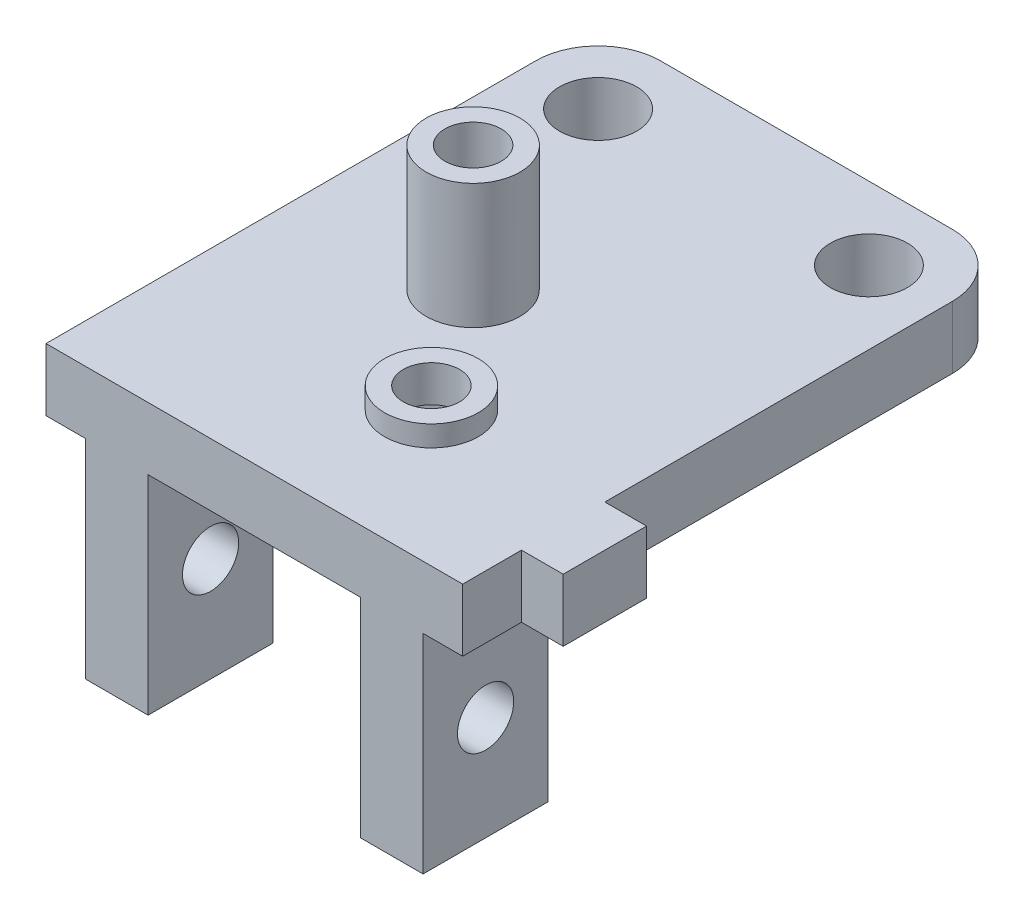
from build123d import *

# Parameters (mm, degrees)
BOSS_EXTRUDE1_DEPTH   = 6
SKETCH16_R            = 4.5
BOSS_EXTRUDE3_DEPTH   = 12
SKETCH16_3_R          = 4.5
BOSS_EXTRUDE4_DEPTH   = 2
CUT_EXTRUDE1_DEPTH    = 4.5
F_5_4MM_DOWEL_HOLE1_D = 5.4
F_7_4MM_DOWEL_HOLE2_D = 7.4
SKETCH2_W             = 6
SKETCH2_H             = 12
BOSS_EXTRUDE2_DEPTH   = 20
F_5_4MM_DOWEL_HOLE3_D = 5.4
FILLET1_R             = 6


with BuildPart() as part:
    # Sketch1 → Boss-Extrude1 (new body)
    with BuildSketch(Plane(origin=(0, 0, 0), x_dir=(1, 0, 0), z_dir=(0, 1, 0))):
        Polygon((40, 5.65), (40, 0), (0, 0), (0, 53), (40, 53), (40, 13.65), (44, 13.65), (44, 5.65), align=None)
    extrude(amount=BOSS_EXTRUDE1_DEPTH)

    # Sketch16 → Boss-Extrude3 (add)
    with BuildSketch(Plane(origin=(0, 6, 0), x_dir=(1, 0, 0), z_dir=(0, 1, 0))):
        with Locations((16, 25)):
            Circle(SKETCH16_R)
    extrude(amount=BOSS_EXTRUDE3_DEPTH)

    # Sketch16_3 → Boss-Extrude4 (add)
    with BuildSketch(Plane(origin=(0, 6, 0), x_dir=(1, 0, 0), z_dir=(0, 1, 0))):
        with Locations((24, 13)):
            Circle(SKETCH16_3_R)
    extrude(amount=BOSS_EXTRUDE4_DEPTH)

    # Sketch12 → Cut-Extrude1 (cut)
    with BuildSketch(Plane.XZ):
        Polygon((28.2, -10.575128869), (24, -8.150257739), (19.8, -10.575128869), (19.8, -15.424871131), (24, -17.849742261), (28.2, -15.424871131), align=None)
        Polygon((16, -20.150257739), (11.8, -22.575128869), (11.8, -27.424871131), (16, -29.849742261), (20.2, -27.424871131), (20.2, -22.575128869), align=None)
    extrude(amount=-CUT_EXTRUDE1_DEPTH, mode=Mode.SUBTRACT)

    # Ø5.4mm Dowel Hole1 (through all)
    with Locations(Plane(origin=(0, 0, 0), x_dir=(-1, 0, 0), z_dir=(0, -1, 0))):
        with Locations((-16, 25), (-24, 13)):
            Hole(F_5_4MM_DOWEL_HOLE1_D / 2)

    # Ø7.4mm Dowel Hole2 (through all)
    with Locations(Plane(origin=(0, 6, 0), x_dir=(1, 0, 0), z_dir=(0, 1, 0))):
        with Locations((7, 46)):
            f_7_4mm_dowel_hole2 = Hole(F_7_4MM_DOWEL_HOLE2_D / 2)

    # Sketch2 → Boss-Extrude2 (add)
    with BuildSketch(Plane.XZ):
        with Locations((6.8, -6)):
            Rectangle(SKETCH2_W, SKETCH2_H)
    boss_extrude2 = extrude(amount=BOSS_EXTRUDE2_DEPTH)

    # Ø5.4mm Dowel Hole3 (through all)
    with Locations(Plane(origin=(9.8, 0, 0), x_dir=(0, 0, -1), z_dir=(1, 0, 0))):
        with Locations((6, -10)):
            f_5_4mm_dowel_hole3 = Hole(F_5_4MM_DOWEL_HOLE3_D / 2)

    # Mirror1: Ø7.4mm Dowel Hole2, Boss-Extrude2, Ø5.4mm Dowel Hole3 across plane
    add(f_7_4mm_dowel_hole2.mirror(Plane(origin=(20, 0, 0), x_dir=(0, 0, 1), z_dir=(1, 0, 0))), mode=Mode.SUBTRACT)
    add(boss_extrude2.mirror(Plane(origin=(20, 0, 0), x_dir=(0, 0, 1), z_dir=(1, 0, 0))))
    add(f_5_4mm_dowel_hole3.mirror(Plane(origin=(20, 0, 0), x_dir=(0, 0, 1), z_dir=(1, 0, 0))), mode=Mode.SUBTRACT)

    # Fillet1
    fillet1_edges = [part.edges().sort_by_distance(p)[0] for p in [
        (0, 3, -53),
        (40, 3, -53),
    ]]
    fillet(fillet1_edges, radius=FILLET1_R)


solid = part.part
